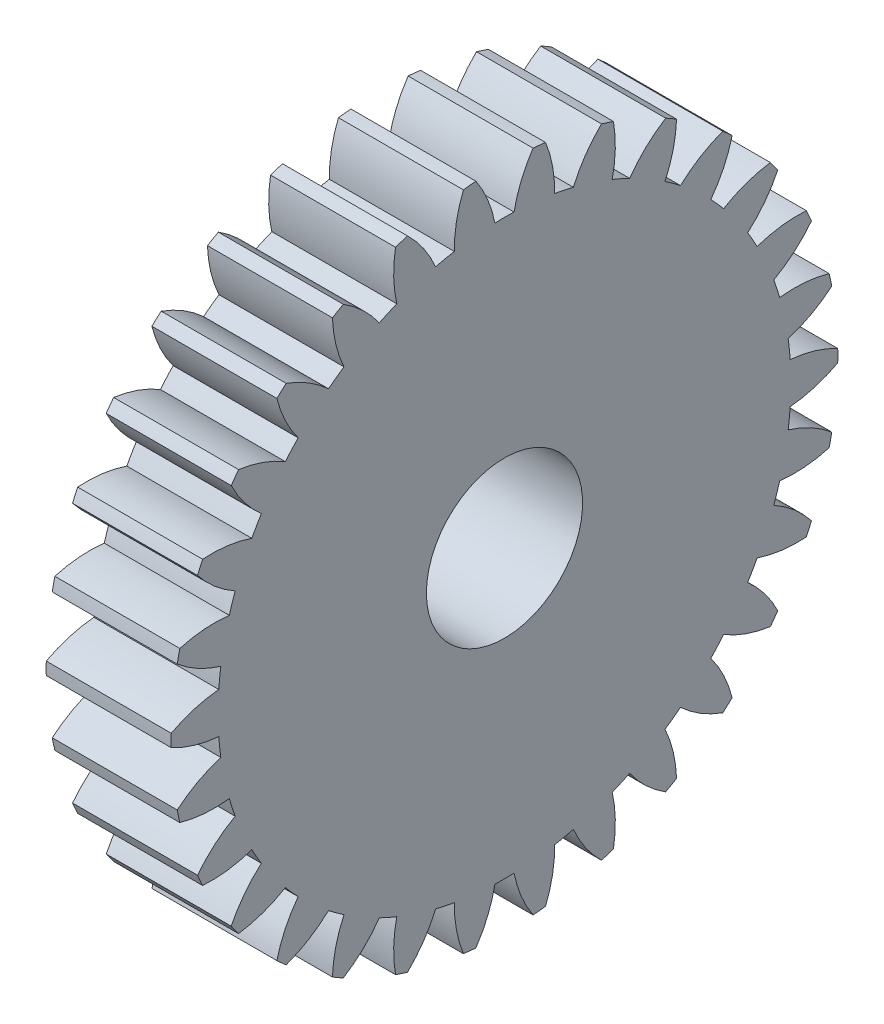
from build123d import *

# Parameters (mm, degrees)
BASPROSKE_W     = 12
BASPROSKE_H     = 32
TOOTHCUT_DEPTH  = 13
TEETHCUTS_COUNT = 30
TEETHCUTS_ANGLE = 348
BORSKE_R        = 7.5
BORE_DEPTH      = 50.0000508


with BuildPart() as part:
    # BasProSke → Base-Revolve (revolve)
    with BuildSketch(Plane(origin=(0, 0, 0), x_dir=(1, 0, 0), z_dir=(0, 1, 0))):
        with Locations((6, 16)):
            Rectangle(BASPROSKE_W, BASPROSKE_H)
    revolve(axis=Axis((-10, 0, 0), (1, 0, 0)))

    # TooCutSke → ToothCut (cut, through all)
    with BuildSketch(Plane(origin=(0, 0, 0), x_dir=(0, 0, -1), z_dir=(1, 0, 0))):
        with BuildLine():
            ThreePointArc((0.918551563, 27.483654488), (0, 27.499), (-0.918551563, 27.483654488))
            ThreePointArc((-0.918551563, 27.483654488), (-1.617208176, 29.787801627), (-2.761784709, 31.906093311))
            ThreePointArc((-2.761784709, 31.906093311), (0, 32.0254), (2.761784709, 31.906093311))
            ThreePointArc((2.761784709, 31.906093311), (1.617208176, 29.787801627), (0.918551563, 27.483654488))
        make_face()
    toothcut = extrude(amount=TOOTHCUT_DEPTH, mode=Mode.SUBTRACT)

    # TeethCuts: ToothCut ×30 about axis
    teethcuts_axis = Axis((-10, 0, 0), (1, 0, 0))
    for i in range(1, TEETHCUTS_COUNT):
        add(toothcut.rotate(teethcuts_axis, i * TEETHCUTS_ANGLE / (TEETHCUTS_COUNT - 1)), mode=Mode.SUBTRACT)

    # BorSke → Bore (cut, symmetric)
    with BuildSketch(Plane(origin=(0, 0, 0), x_dir=(0, 0, -1), z_dir=(1, 0, 0))):
        Circle(BORSKE_R)
    extrude(amount=BORE_DEPTH, both=True, mode=Mode.SUBTRACT)


solid = part.part
